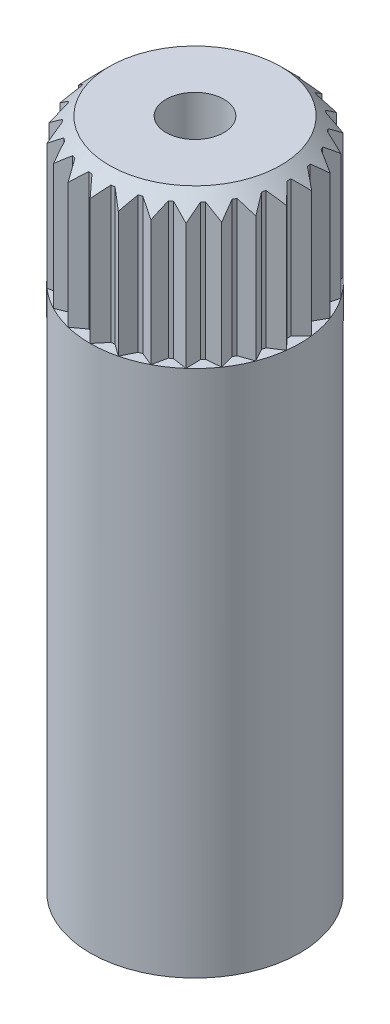
from build123d import *

# Parameters (mm, degrees)
SKETCH12_R          = 2.9
BOSS_EXTRUDE4_DEPTH = 14.6
SKETCH13_R          = 2.6
BOSS_EXTRUDE5_DEPTH = 4
BOSS_EXTRUDE6_DEPTH = 18.6
CIRPATTERN1_COUNT   = 26
SKETCH16_R          = 0.8
CUT_EXTRUDE1_DEPTH  = 4


with BuildPart() as part:
    # Sketch12 → Boss-Extrude4 (new body)
    with BuildSketch(Plane(origin=(0, 0, 0), x_dir=(1, 0, 0), z_dir=(0, 1, 0))):
        Circle(SKETCH12_R)
    extrude(amount=BOSS_EXTRUDE4_DEPTH)

    # Sketch13 → Boss-Extrude5 (add)
    with BuildSketch(Plane(origin=(0, 14.6, 0), x_dir=(1, 0, 0), z_dir=(0, 1, 0))):
        Circle(SKETCH13_R)
    extrude(amount=BOSS_EXTRUDE5_DEPTH)

    # Sketch14 → Boss-Extrude6 (add)
    with BuildSketch(Plane(origin=(0, 18.6, 0), x_dir=(1, 0, 0), z_dir=(0, 1, 0))):
        with BuildLine():
            Line((0, 2.9), (-0.262912611, 2.586672952))
            ThreePointArc((-0.262912611, 2.586672952), (0, 2.6), (0.262912611, 2.586672952))
            Line((0.262912611, 2.586672952), (0, 2.9))
        make_face()
    boss_extrude6 = extrude(amount=-BOSS_EXTRUDE6_DEPTH)

    # CirPattern1: Boss-Extrude6 ×26 about axis
    cirpattern1_axis = Axis((0, 0, 0), (0, 1, 0))
    for i in range(1, CIRPATTERN1_COUNT):
        add(boss_extrude6.rotate(cirpattern1_axis, i * 360 / CIRPATTERN1_COUNT))

    # Sketch15 → Cut-Revolve1 (revolve, cut)
    with BuildSketch(Plane(origin=(0, 0, 0), x_dir=(0, 0, -1), z_dir=(1, 0, 0))):
        Polygon((2.9, 18.069669914), (2.9, 18.6), (2.369669914, 18.6), align=None)
    revolve(axis=Axis((0, 18.6, 0), (0, -1, 0)), mode=Mode.SUBTRACT)

    # Sketch16 → Cut-Extrude1 (cut)
    with BuildSketch(Plane(origin=(0, 18.6, 0), x_dir=(1, 0, 0), z_dir=(0, 1, 0))):
        Circle(SKETCH16_R)
    extrude(amount=-CUT_EXTRUDE1_DEPTH, mode=Mode.SUBTRACT)


solid = part.part
